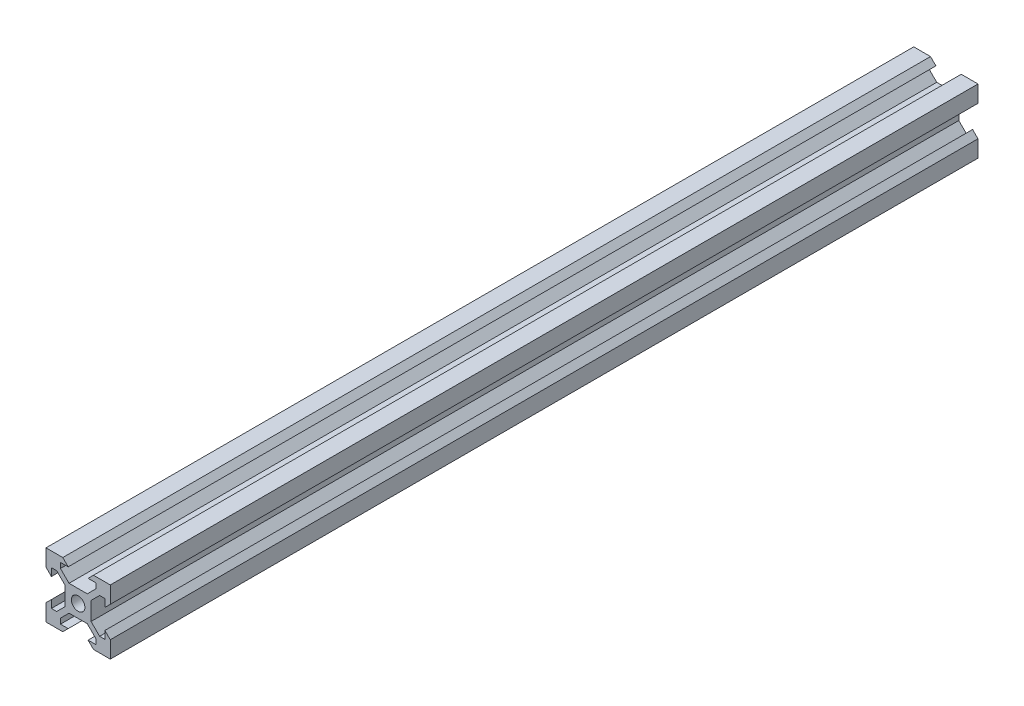
from build123d import *

# Parameters (mm, degrees)
SKETCH2_R           = 2.1
BOSS_EXTRUDE1_DEPTH = 270


with BuildPart() as part:
    # Sketch2 → Boss-Extrude1 (new body)
    with BuildSketch(Plane.XY):
        Polygon((-4.775, 10), (-3.1, 8.325), (-5.5, 8.325), (-5.5, 6.685), (-2.84, 4.025), (2.84, 4.025), (5.5, 6.685), (5.5, 8.325), (3.1, 8.325), (4.775, 10), (10, 10), (10, 4.775), (8.325, 3.1), (8.325, 5.5), (6.685, 5.5), (4.025, 2.84), (4.025, -2.84), (6.685, -5.5), (8.325, -5.5), (8.325, -3.1), (10, -4.775), (10, -10), (4.775, -10), (3.1, -8.325), (5.5, -8.325), (5.5, -6.685), (2.84, -4.025), (-2.84, -4.025), (-5.5, -6.685), (-5.5, -8.325), (-3.1, -8.325), (-4.775, -10), (-10, -10), (-10, -4.775), (-8.325, -3.1), (-8.325, -5.5), (-6.685, -5.5), (-4.025, -2.84), (-4.025, 2.84), (-6.685, 5.5), (-8.325, 5.5), (-8.325, 3.1), (-10, 4.775), (-10, 10), align=None)
        Circle(SKETCH2_R, mode=Mode.SUBTRACT)
    extrude(amount=BOSS_EXTRUDE1_DEPTH)


solid = part.part
